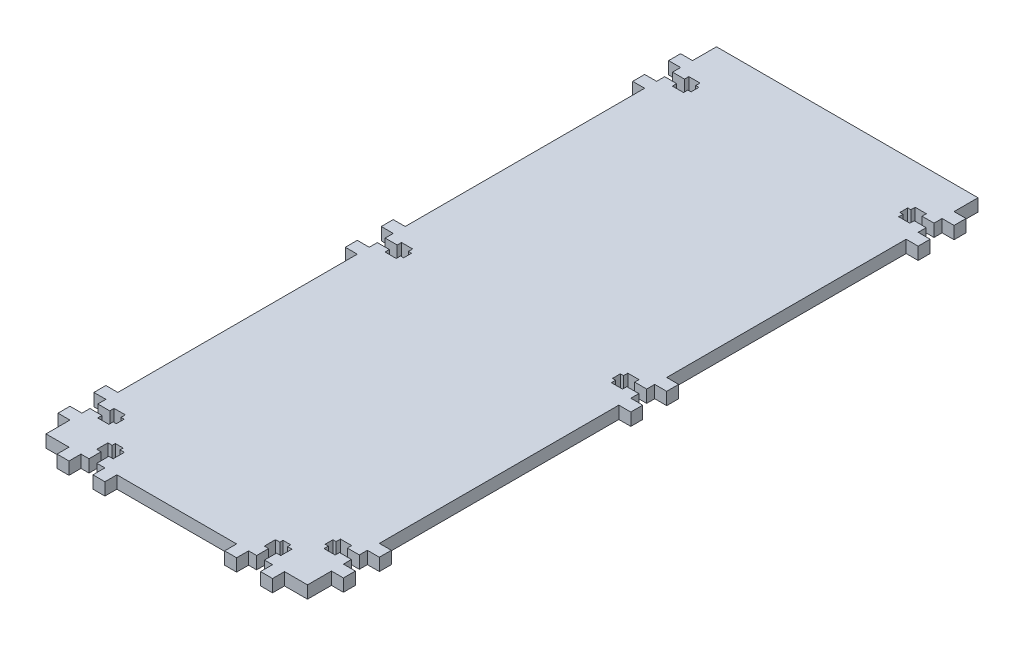
from build123d import *

# Parameters (mm, degrees)
SKETCH1_W           = 138.684
SKETCH1_H           = 355.6
BOSS_EXTRUDE1_DEPTH = 6.604
CUT_EXTRUDE1_DEPTH  = 7.604
SKETCH5_W           = 6.35
SKETCH5_H           = 6.35
BOSS_EXTRUDE2_DEPTH = 6.604


with BuildPart() as part:
    # Sketch1 → Boss-Extrude1 (new body)
    with BuildSketch(Plane(origin=(0, 0, 0), x_dir=(1, 0, 0), z_dir=(0, 1, 0))):
        Rectangle(SKETCH1_W, SKETCH1_H)
    extrude(amount=BOSS_EXTRUDE1_DEPTH)

    # Sketch4 → Cut-Extrude1 (cut, through all)
    with BuildSketch(Plane(origin=(0, 6.604, 0), x_dir=(1, 0, 0), z_dir=(0, 1, 0))):
        Polygon((-62.992, 154.4828), (-69.342, 154.4828), (-69.342, 150.3172), (-62.992, 150.3172), (-62.992, 148.0312), (-57.0484, 148.0312), (-57.0484, 150.3172), (-55.372, 150.3172), (-55.372, 154.4828), (-57.0484, 154.4828), (-57.0484, 156.7688), (-62.992, 156.7688), align=None)
        Polygon((57.0484, 154.4828), (55.372, 154.4828), (55.372, 150.3172), (57.0484, 150.3172), (57.0484, 148.0312), (62.992, 148.0312), (62.992, 150.3172), (69.342, 150.3172), (69.342, 154.4828), (62.992, 154.4828), (62.992, 156.7688), (57.0484, 156.7688), align=None)
        Polygon((-62.992, 2.0828), (-69.342, 2.0828), (-69.342, -2.0828), (-62.992, -2.0828), (-62.992, -4.3688), (-57.0484, -4.3688), (-57.0484, -2.0828), (-55.372, -2.0828), (-55.372, 2.0828), (-57.0484, 2.0828), (-57.0484, 4.3688), (-62.992, 4.3688), align=None)
        Polygon((69.342, 2.0828), (62.992, 2.0828), (62.992, 4.3688), (57.0484, 4.3688), (57.0484, 2.0828), (55.372, 2.0828), (55.372, -2.0828), (57.0484, -2.0828), (57.0484, -4.3688), (62.992, -4.3688), (62.992, -2.0828), (69.342, -2.0828), align=None)
        Polygon((-62.992, -150.3172), (-69.342, -150.3172), (-69.342, -154.4828), (-62.992, -154.4828), (-62.992, -156.7688), (-57.0484, -156.7688), (-57.0484, -154.4828), (-55.372, -154.4828), (-55.372, -150.3172), (-57.0484, -150.3172), (-57.0484, -148.0312), (-62.992, -148.0312), align=None)
        Polygon((69.342, -150.3172), (62.992, -150.3172), (62.992, -148.0312), (57.0484, -148.0312), (57.0484, -150.3172), (55.372, -150.3172), (55.372, -154.4828), (57.0484, -154.4828), (57.0484, -156.7688), (62.992, -156.7688), (62.992, -154.4828), (69.342, -154.4828), align=None)
        Polygon((-46.5328, -165.5064), (-48.8188, -165.5064), (-48.8188, -171.45), (-46.5328, -171.45), (-46.5328, -177.8), (-42.3672, -177.8), (-42.3672, -171.45), (-40.0812, -171.45), (-40.0812, -165.5064), (-42.3672, -165.5064), (-42.3672, -163.83), (-46.5328, -163.83), align=None)
        Polygon((48.8188, -165.5064), (46.5328, -165.5064), (46.5328, -163.83), (42.3672, -163.83), (42.3672, -165.5064), (40.0812, -165.5064), (40.0812, -171.45), (42.3672, -171.45), (42.3672, -177.8), (46.5328, -177.8), (46.5328, -171.45), (48.8188, -171.45), align=None)
    extrude(amount=-CUT_EXTRUDE1_DEPTH, mode=Mode.SUBTRACT)

    # Sketch5 → Boss-Extrude2 (add)
    with BuildSketch(Plane(origin=(0, 6.604, 0), x_dir=(1, 0, 0), z_dir=(0, 1, 0))):
        with Locations((-72.517, 161.925)):
            Rectangle(SKETCH5_W, SKETCH5_H)
        with Locations((-72.517, 142.875)):
            Rectangle(SKETCH5_W, SKETCH5_H)
        with Locations((72.517, 161.925)):
            Rectangle(SKETCH5_W, SKETCH5_H)
        with Locations((72.517, 142.875)):
            Rectangle(SKETCH5_W, SKETCH5_H)
        with Locations((-72.517, 9.525)):
            Rectangle(SKETCH5_W, SKETCH5_H)
        with Locations((-72.517, -9.525)):
            Rectangle(SKETCH5_W, SKETCH5_H)
        with Locations((-72.517, -142.875)):
            Rectangle(SKETCH5_W, SKETCH5_H)
        with Locations((-72.517, -161.925)):
            Rectangle(SKETCH5_W, SKETCH5_H)
        with Locations((72.517, -161.925)):
            Rectangle(SKETCH5_W, SKETCH5_H)
        with Locations((72.517, -142.875)):
            Rectangle(SKETCH5_W, SKETCH5_H)
        with Locations((72.517, -9.525)):
            Rectangle(SKETCH5_W, SKETCH5_H)
        with Locations((72.517, 9.525)):
            Rectangle(SKETCH5_W, SKETCH5_H)
        with Locations((-53.975, -180.975)):
            Rectangle(SKETCH5_W, SKETCH5_H)
        with Locations((-34.925, -180.975)):
            Rectangle(SKETCH5_W, SKETCH5_H)
        with Locations((34.925, -180.975)):
            Rectangle(SKETCH5_W, SKETCH5_H)
        with Locations((53.975, -180.975)):
            Rectangle(SKETCH5_W, SKETCH5_H)
    extrude(amount=-BOSS_EXTRUDE2_DEPTH)


solid = part.part
